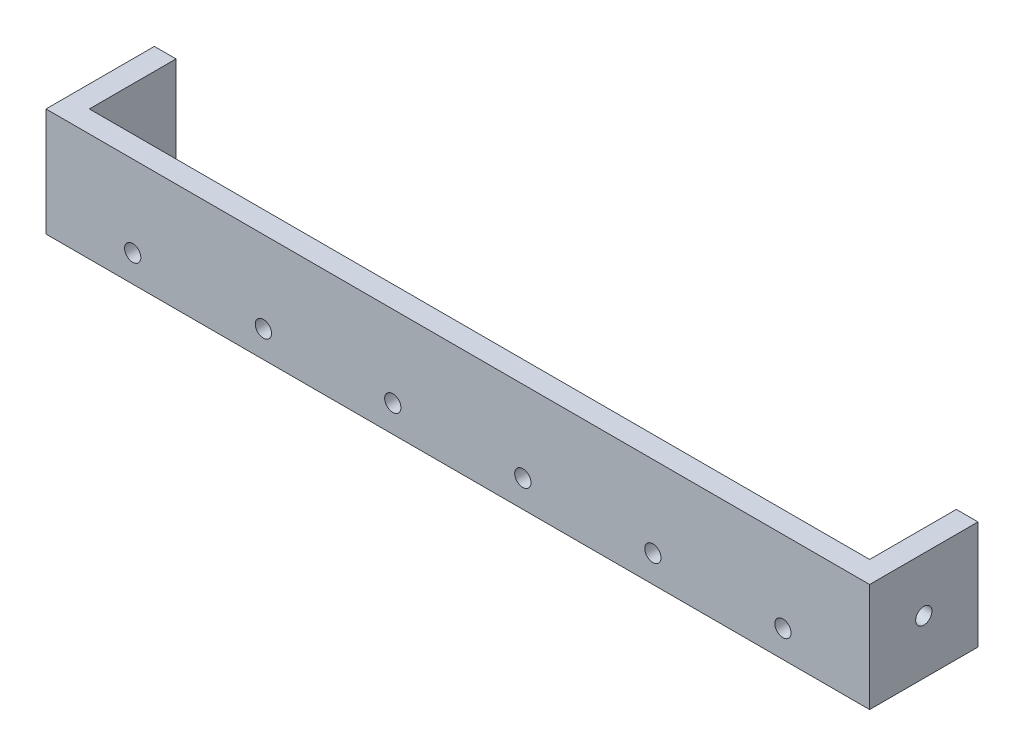
from build123d import *

# Parameters (mm, degrees)
SKETCH1_W           = 72
SKETCH1_H           = 10
BOSS_EXTRUDE1_DEPTH = 2
SKETCH3_R           = 0.75
CUT_EXTRUDE2_DEPTH  = 2
SKETCH4_W           = 10
SKETCH4_H           = 10
BOSS_EXTRUDE2_DEPTH = 2
SKETCH5_R           = 0.75
CUT_EXTRUDE4_DEPTH  = 2
SKETCH6_W           = 10
SKETCH6_H           = 10
BOSS_EXTRUDE3_DEPTH = 2
SKETCH7_R           = 0.75
CUT_EXTRUDE5_DEPTH  = 2


with BuildPart() as part:
    # Sketch1 → Boss-Extrude1 (new body)
    with BuildSketch(Plane.XY):
        with Locations((36, 5)):
            Rectangle(SKETCH1_W, SKETCH1_H)
    extrude(amount=BOSS_EXTRUDE1_DEPTH)

    # Sketch3 → Cut-Extrude2 (cut)
    with BuildSketch(Plane.XY):
        with Locations((42, 2.5)):
            Circle(SKETCH3_R)
        with Locations((54, 2.5)):
            Circle(SKETCH3_R)
        with Locations((66, 2.5)):
            Circle(SKETCH3_R)
        with Locations((30, 2.5)):
            Circle(SKETCH3_R)
        with Locations((18.06024044, 2.463599586)):
            Circle(SKETCH3_R)
        with Locations((6, 2.5)):
            Circle(SKETCH3_R)
    extrude(amount=CUT_EXTRUDE2_DEPTH, mode=Mode.SUBTRACT)

    # Sketch4 → Boss-Extrude2 (add)
    with BuildSketch(Plane(origin=(72, 0, 0), x_dir=(0, 0, -1), z_dir=(1, 0, 0))):
        with Locations((3, 5)):
            Rectangle(SKETCH4_W, SKETCH4_H)
    extrude(amount=BOSS_EXTRUDE2_DEPTH)

    # Sketch5 → Cut-Extrude4 (cut)
    with BuildSketch(Plane(origin=(72, 0, 0), x_dir=(0, 0, -1), z_dir=(1, 0, 0))):
        with Locations((3, 5)):
            Circle(SKETCH5_R)
    extrude(amount=CUT_EXTRUDE4_DEPTH, mode=Mode.SUBTRACT)

    # Sketch6 → Boss-Extrude3 (add)
    with BuildSketch(Plane.ZY):
        with Locations((-3, 5)):
            Rectangle(SKETCH6_W, SKETCH6_H)
    extrude(amount=BOSS_EXTRUDE3_DEPTH)

    # Sketch7 → Cut-Extrude5 (cut)
    with BuildSketch(Plane.ZY):
        with Locations((-3, 2.5)):
            Circle(SKETCH7_R)
    extrude(amount=CUT_EXTRUDE5_DEPTH, mode=Mode.SUBTRACT)


solid = part.part
